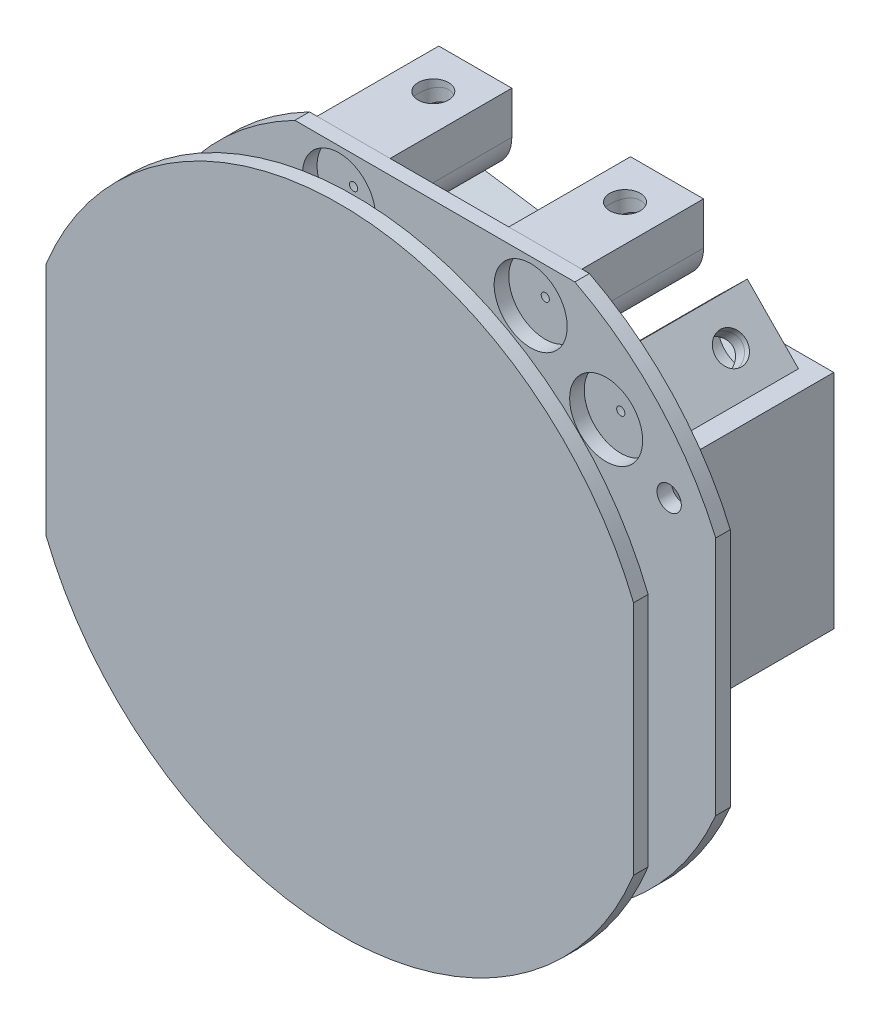
from build123d import *

# Parameters (mm, degrees)
SKETCH1_R                      = 1
SKETCH1_R_2                    = 3
BOSS_EXTRUDE1_DEPTH            = 1.2
SKETCH1_2_R                    = 3
BOSS_EXTRUDE2_DEPTH            = 10
BOSS_EXTRUDE2_2_DEPTH          = 10
BOSS_EXTRUDE2_3_DEPTH          = 10
BOSS_EXTRUDE2_4_DEPTH          = 10
BOSS_EXTRUDE4_DEPTH            = 1.2
BOSS_EXTRUDE7_DEPTH            = 10
BOSS_EXTRUDE7_2_DEPTH          = 10
BOSS_EXTRUDE7_3_DEPTH          = 10
BOSS_EXTRUDE7_4_DEPTH          = 10
F_4_0MM_DOWEL_HOLE3_AT_2_COUNT = 2
F_4_0MM_DOWEL_HOLE3_AT_2_PITCH = 7.964923101
F_4_0MM_DOWEL_HOLE3_AT_3_COUNT = 2
F_4_0MM_DOWEL_HOLE3_AT_3_PITCH = 22.51227443
F_4_0MM_DOWEL_HOLE3_AT_4_COUNT = 2
F_4_0MM_DOWEL_HOLE3_AT_4_PITCH = 28.15
SKETCH9_W                      = 10
SKETCH9_H                      = 18.25
BOSS_EXTRUDE8_DEPTH            = 15.5


with BuildPart() as part:
    # Sketch1 → Boss-Extrude1 (new body)
    with BuildSketch(Plane.XY):
        with BuildLine():
            Line((-23.075, 9.87632127), (-23.075, -9.87632127))
            ThreePointArc((-23.075, -9.87632127), (0, -25.099747943), (23.075, -9.87632127))
            Line((23.075, -9.87632127), (23.075, 9.87632127))
            ThreePointArc((23.075, 9.87632127), (18.371399374, 17.102310717), (11.5, 22.310252057))
            Line((11.5, 22.310252057), (-11.5, 22.310252057))
            ThreePointArc((-11.5, 22.310252057), (-18.371399374, 17.102310717), (-23.075, 9.87632127))
        make_face()
        with Locations((-19.25, 10.810252057)):
            Circle(SKETCH1_R, mode=Mode.SUBTRACT)
        with Locations(Location((19.25, 10.810252057, 0), (0, 0, 180))):
            Circle(SKETCH1_R, mode=Mode.SUBTRACT)
        with Locations((0, -22.389747943)):
            Circle(SKETCH1_R, mode=Mode.SUBTRACT)
        with Locations((-14.075, 13.810252057)):
            Circle(SKETCH1_R_2, mode=Mode.SUBTRACT)
        with Locations((-7.875, 18.810252057)):
            Circle(SKETCH1_R_2, mode=Mode.SUBTRACT)
        with Locations((7.875, 18.810252057)):
            Circle(SKETCH1_R_2, mode=Mode.SUBTRACT)
        with Locations(Location((14.075, 13.810252057, 0), (0, 0, 180))):
            Circle(SKETCH1_R_2, mode=Mode.SUBTRACT)
    extrude(amount=BOSS_EXTRUDE1_DEPTH)

    # Sketch9 → Boss-Extrude8 (add)
    with BuildSketch(Plane(origin=(0, 0, 0), x_dir=(-1, 0, 0), z_dir=(0, 0, -1))):
        with Locations((-11.075, 0.685252057)):
            Rectangle(SKETCH9_W, SKETCH9_H)
        Polygon((16.725, 10.460252057), (19.375, -7.596325692), (9.480984795, -9.048380487), (6.830984795, 9.008197262), align=None)
    extrude(amount=BOSS_EXTRUDE8_DEPTH)


with BuildPart() as body_2:
    # Sketch1_2 → Boss-Extrude2 (new body)
    with BuildSketch(Plane.XY):
        with Locations((-7.875, 18.810252057)):
            Circle(SKETCH1_2_R)
    extrude(amount=-BOSS_EXTRUDE2_DEPTH)


with BuildPart() as body_3:
    # Sketch1_2 → Boss-Extrude2 2 (new body)
    with BuildSketch(Plane.XY):
        with Locations((-14.075, 13.810252057)):
            Circle(SKETCH1_2_R)
    extrude(amount=-BOSS_EXTRUDE2_2_DEPTH)

    # Sketch8 → Ø4.0mm Dowel Hole3 (revolve, cut)
    with BuildSketch(Plane(origin=(-14.075, 13.810252057, -10), x_dir=(0, 1, 0), z_dir=(1, 0, 0))):
        Polygon((0, 0), (0, 10.201721238), (2, 9), (2, 0), align=None)
    f_4_0mm_dowel_hole3 = revolve(axis=Axis((-14.075, 13.810252057, -16.35), (0, 0, 1)), mode=Mode.SUBTRACT)


with BuildPart() as body_4:
    # Sketch1_2 → Boss-Extrude2 3 (new body)
    with BuildSketch(Plane.XY):
        with Locations((7.875, 18.810252057)):
            Circle(SKETCH1_2_R)
    extrude(amount=-BOSS_EXTRUDE2_3_DEPTH)

    # Ø4.0mm Dowel Hole3 at 3: Ø4.0mm Dowel Hole3 ×2
    with Locations(*[Vector(0.9750236506979136, 0.22210105938449046, 0) * (i * F_4_0MM_DOWEL_HOLE3_AT_3_PITCH) for i in range(1, F_4_0MM_DOWEL_HOLE3_AT_3_COUNT)]):
        add(f_4_0mm_dowel_hole3, mode=Mode.SUBTRACT)


with BuildPart() as body_5:
    # Sketch1_2 → Boss-Extrude2 4 (new body)
    with BuildSketch(Plane.XY):
        with Locations((14.075, 13.810252057)):
            Circle(SKETCH1_2_R)
    extrude(amount=-BOSS_EXTRUDE2_4_DEPTH)

    # Ø4.0mm Dowel Hole3 at 4: Ø4.0mm Dowel Hole3 ×2
    with Locations(*[(i * F_4_0MM_DOWEL_HOLE3_AT_4_PITCH, 0, 0) for i in range(1, F_4_0MM_DOWEL_HOLE3_AT_4_COUNT)]):
        add(f_4_0mm_dowel_hole3, mode=Mode.SUBTRACT)


with BuildPart() as body_6:
    # Sketch3 → Boss-Extrude4 (new body)
    with BuildSketch(Plane(origin=(0, 0, 9), x_dir=(-1, 0, 0), z_dir=(0, 0, -1))):
        with BuildLine():
            Line((-24.125, 9.694553883), (-24.125, -9.694553883))
            ThreePointArc((-24.125, -9.694553883), (0, -26), (24.125, -9.694553883))
            Line((24.125, -9.694553883), (24.125, 9.694553883))
            ThreePointArc((24.125, 9.694553883), (0, 26), (-24.125, 9.694553883))
        make_face()
    extrude(amount=BOSS_EXTRUDE4_DEPTH)


with BuildPart() as body_7:
    # Sketch5 → Boss-Extrude7 (new body)
    with BuildSketch(Plane(origin=(0, 0, -10), x_dir=(-1, 0, 0), z_dir=(0, 0, -1))):
        with BuildLine():
            Line((-14.472172641, 18.402882446), (-18.674343495, 14.12015433))
            Line((-18.674343495, 14.12015433), (-16.176085427, 11.668887999))
            ThreePointArc((-16.176085427, 11.668887999), (-16.216364058, 15.911337484), (-11.973914573, 15.951616114))
            Line((-11.973914573, 15.951616114), (-14.472172641, 18.402882446))
        make_face()
    extrude(amount=-BOSS_EXTRUDE7_DEPTH)


with BuildPart() as body_8:
    # Sketch5 → Boss-Extrude7 2 (new body)
    with BuildSketch(Plane(origin=(0, 0, -10), x_dir=(-1, 0, 0), z_dir=(0, 0, -1))):
        with BuildLine():
            Line((-10.875, 22.310252057), (-10.875, 18.810252057))
            ThreePointArc((-10.875, 18.810252057), (-7.875, 21.810252057), (-4.875, 18.810252057))
            Line((-4.875, 18.810252057), (-4.875, 22.310252057))
            Line((-4.875, 22.310252057), (-10.875, 22.310252057))
        make_face()
    extrude(amount=-BOSS_EXTRUDE7_2_DEPTH)


with BuildPart() as body_9:
    # Sketch5 → Boss-Extrude7 3 (new body)
    with BuildSketch(Plane(origin=(0, 0, -10), x_dir=(-1, 0, 0), z_dir=(0, 0, -1))):
        with BuildLine():
            Line((4.875, 22.310252057), (4.875, 18.810252057))
            ThreePointArc((4.875, 18.810252057), (7.875, 21.810252057), (10.875, 18.810252057))
            Line((10.875, 18.810252057), (10.875, 22.310252057))
            Line((10.875, 22.310252057), (4.875, 22.310252057))
        make_face()
    extrude(amount=-BOSS_EXTRUDE7_3_DEPTH)


with BuildPart() as body_10:
    # Sketch5 → Boss-Extrude7 4 (new body)
    with BuildSketch(Plane(origin=(0, 0, -10), x_dir=(-1, 0, 0), z_dir=(0, 0, -1))):
        with BuildLine():
            Line((18.674343495, 14.12015433), (14.472172641, 18.402882446))
            Line((14.472172641, 18.402882446), (11.973914573, 15.951616114))
            ThreePointArc((11.973914573, 15.951616114), (15.236194152, 16.576409706), (17.075, 13.810252057))
            ThreePointArc((17.075, 13.810252057), (16.841157649, 12.649057904), (16.176085427, 11.668887999))
            Line((16.176085427, 11.668887999), (18.674343495, 14.12015433))
        make_face()
    extrude(amount=-BOSS_EXTRUDE7_4_DEPTH)


with BuildPart() as body_2_1:
    add(body_2.part)

    # Ø4.0mm Dowel Hole3 at 2: Ø4.0mm Dowel Hole3 ×2
    with Locations(*[Vector(0.7784130394753294, 0.6277524511897818, 0) * (i * F_4_0MM_DOWEL_HOLE3_AT_2_PITCH) for i in range(1, F_4_0MM_DOWEL_HOLE3_AT_2_COUNT)]):
        add(f_4_0mm_dowel_hole3, mode=Mode.SUBTRACT)


with BuildPart() as f_2_5_2_5_diameter_hole1_tool:
    # Sketch14 → Ø2.5 (2.5) Diameter Hole1 (revolve)
    with BuildSketch(Plane(origin=(16.573258068, 16.261518388, -6.55), x_dir=(-0.7003618089916359, 0.713788019306827, 0), z_dir=(0, 0, 1))):
        Polygon((0, 0), (0, 3.751075774), (1.25, 3), (1.25, 0), align=None)
    revolve(axis=Axis((21.10581199, 20.708815875, -6.55), (-0.713788019306827, -0.7003618089916359, 0)))


with BuildPart() as body_5_1:
    add(body_5.part)

    # Ø2.5 (2.5) Diameter Hole1: cut by f_2_5_2_5_diameter_hole1_tool
    add(f_2_5_2_5_diameter_hole1_tool.part, mode=Mode.SUBTRACT)


with BuildPart() as body_7_1:
    add(body_7.part)

    # Ø2.5 (2.5) Diameter Hole1: cut by f_2_5_2_5_diameter_hole1_tool
    add(f_2_5_2_5_diameter_hole1_tool.part, mode=Mode.SUBTRACT)


with BuildPart() as f_2_5_2_5_diameter_hole1_at_2_tool:
    # Sketch14 at point 2 (carried to point 2, square into its face) → Ø2.5 (2.5) Diameter Hole1 at 2 (revolve)
    with BuildSketch(Plane(origin=(7.875, 22.310252057, -6.55), x_dir=(-1, 0, 0), z_dir=(0, 0, 1))):
        Polygon((0, 0), (0, 3.751075774), (1.25, 3), (1.25, 0), align=None)
    revolve(axis=Axis((7.875, 28.660252057, -6.55), (0, -1, 0)))


with BuildPart() as body_4_1:
    add(body_4.part)

    # Ø2.5 (2.5) Diameter Hole1 at 2: cut by f_2_5_2_5_diameter_hole1_at_2_tool
    add(f_2_5_2_5_diameter_hole1_at_2_tool.part, mode=Mode.SUBTRACT)


with BuildPart() as body_8_1:
    add(body_8.part)

    # Ø2.5 (2.5) Diameter Hole1 at 2: cut by f_2_5_2_5_diameter_hole1_at_2_tool
    add(f_2_5_2_5_diameter_hole1_at_2_tool.part, mode=Mode.SUBTRACT)


with BuildPart() as f_2_5_2_5_diameter_hole1_at_3_tool:
    # Sketch14 at point 3 (carried to point 3, square into its face) → Ø2.5 (2.5) Diameter Hole1 at 3 (revolve)
    with BuildSketch(Plane(origin=(-7.875, 22.310252057, -6.55), x_dir=(-1, 0, 0), z_dir=(0, 0, 1))):
        Polygon((0, 0), (0, 3.751075774), (1.25, 3), (1.25, 0), align=None)
    revolve(axis=Axis((-7.875, 28.660252057, -6.55), (0, -1, 0)))


with BuildPart() as body_2_2:
    add(body_2_1.part)

    # Ø2.5 (2.5) Diameter Hole1 at 3: cut by f_2_5_2_5_diameter_hole1_at_3_tool
    add(f_2_5_2_5_diameter_hole1_at_3_tool.part, mode=Mode.SUBTRACT)


with BuildPart() as body_9_1:
    add(body_9.part)

    # Ø2.5 (2.5) Diameter Hole1 at 3: cut by f_2_5_2_5_diameter_hole1_at_3_tool
    add(f_2_5_2_5_diameter_hole1_at_3_tool.part, mode=Mode.SUBTRACT)


with BuildPart() as f_2_5_2_5_diameter_hole1_at_4_tool:
    # Sketch14 at point 4 (carried to point 4, square into its face) → Ø2.5 (2.5) Diameter Hole1 at 4 (revolve)
    with BuildSketch(Plane(origin=(-16.573258068, 16.261518388, -6.55), x_dir=(-0.700361916, -0.713787914, 0), z_dir=(0, 0, 1))):
        Polygon((0, 0), (0, 3.751075774), (1.25, 3), (1.25, 0), align=None)
    revolve(axis=Axis((-21.105811324, 20.708816554, -6.55), (0.713787914, -0.700361916, 0)))


with BuildPart() as body_3_1:
    add(body_3.part)

    # Ø2.5 (2.5) Diameter Hole1 at 4: cut by f_2_5_2_5_diameter_hole1_at_4_tool
    add(f_2_5_2_5_diameter_hole1_at_4_tool.part, mode=Mode.SUBTRACT)


with BuildPart() as body_10_1:
    add(body_10.part)

    # Ø2.5 (2.5) Diameter Hole1 at 4: cut by f_2_5_2_5_diameter_hole1_at_4_tool
    add(f_2_5_2_5_diameter_hole1_at_4_tool.part, mode=Mode.SUBTRACT)


solid = Compound([part.part, body_6.part, body_5_1.part, body_7_1.part, body_4_1.part, body_8_1.part, body_2_2.part, body_9_1.part, body_3_1.part, body_10_1.part])
